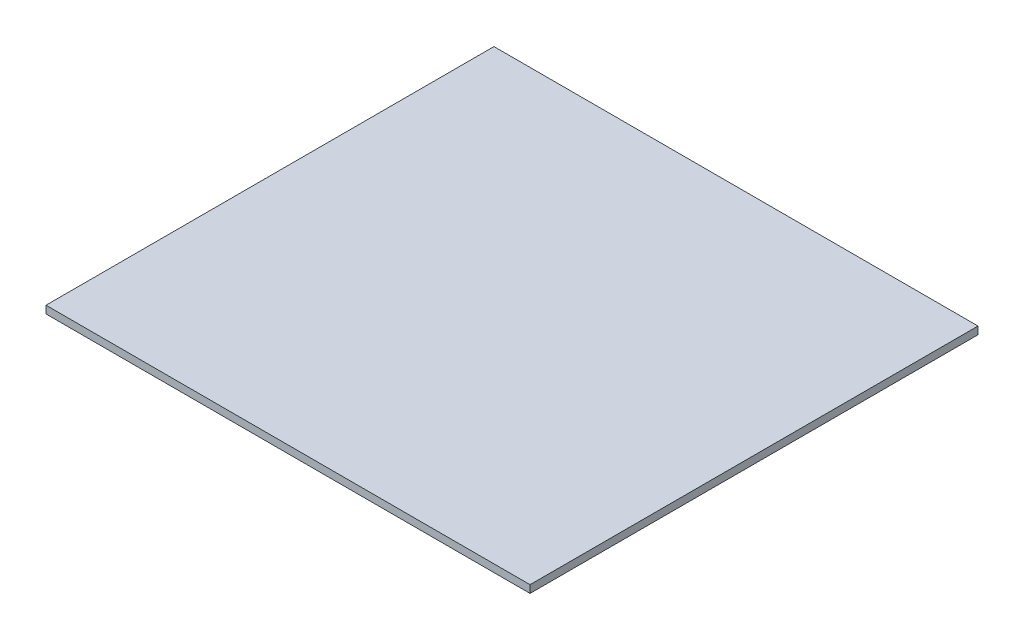
from build123d import *

# Parameters (mm, degrees)
SKETCH1_W           = 809.625
SKETCH1_H           = 749.3
BOSS_EXTRUDE1_DEPTH = 6.35


with BuildPart() as part:
    # Sketch1 → Boss-Extrude1 (new body, symmetric)
    with BuildSketch(Plane(origin=(0, 0, 0), x_dir=(1, 0, 0), z_dir=(0, 1, 0))):
        Rectangle(SKETCH1_W, SKETCH1_H)
    extrude(amount=BOSS_EXTRUDE1_DEPTH, both=True)


solid = part.part
